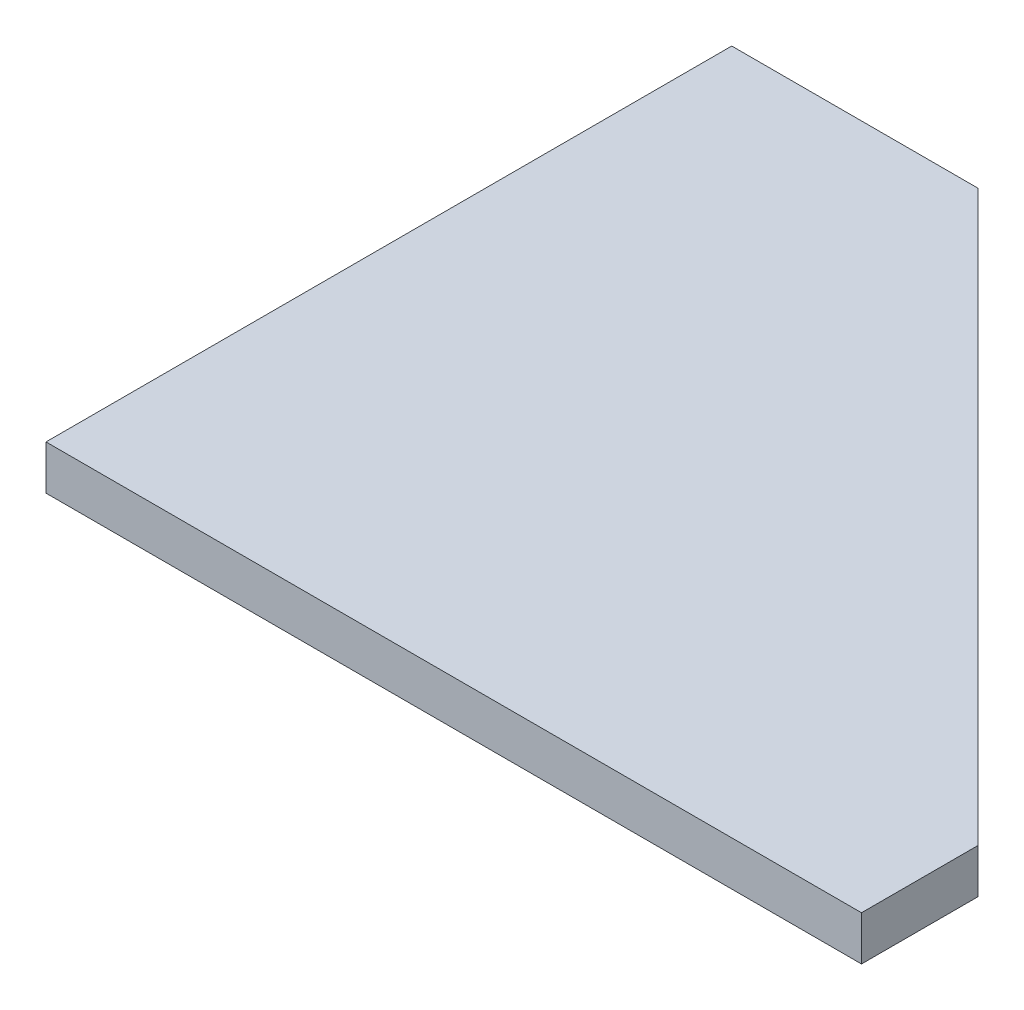
from build123d import *

# Parameters (mm, degrees)
BOSS_EXTRUDE1_DEPTH = 38.1
SKETCH2_W           = 19
SKETCH2_H           = 50
CUT_EXTRUDE1_DEPTH  = 2
CUT_EXTRUDE2_DEPTH  = 20


with BuildPart() as part:
    # Sketch1 → Boss-Extrude1 (new body)
    with BuildSketch(Plane(origin=(0, 0, 0), x_dir=(1, 0, 0), z_dir=(0, 1, 0))):
        Polygon((-138.61, 294.305), (350, -194.305), (350, -294.305), (-350, -294.305), (-350, 294.305), align=None)
    extrude(amount=BOSS_EXTRUDE1_DEPTH)

    # Sketch2 → Cut-Extrude1 (cut)
    with BuildSketch(Plane.XZ):
        with Locations((-340.5, -129.305)):
            Rectangle(SKETCH2_W, SKETCH2_H)
        with Locations((-340.5, 129.305)):
            Rectangle(SKETCH2_W, SKETCH2_H)
    extrude(amount=-CUT_EXTRUDE1_DEPTH, mode=Mode.SUBTRACT)

    # Sketch3 → Cut-Extrude2 (cut)
    with BuildSketch(Plane(origin=(0, 0, 0), x_dir=(1, 0, 0), z_dir=(0, 1, 0))):
        Polygon((-138.61, 294.305), (-181.946540118, 250.968459882), (-146.706941406, 216.891522613), (-104.668874503, 260.363874503), align=None)
    extrude(amount=CUT_EXTRUDE2_DEPTH, mode=Mode.SUBTRACT)


solid = part.part
